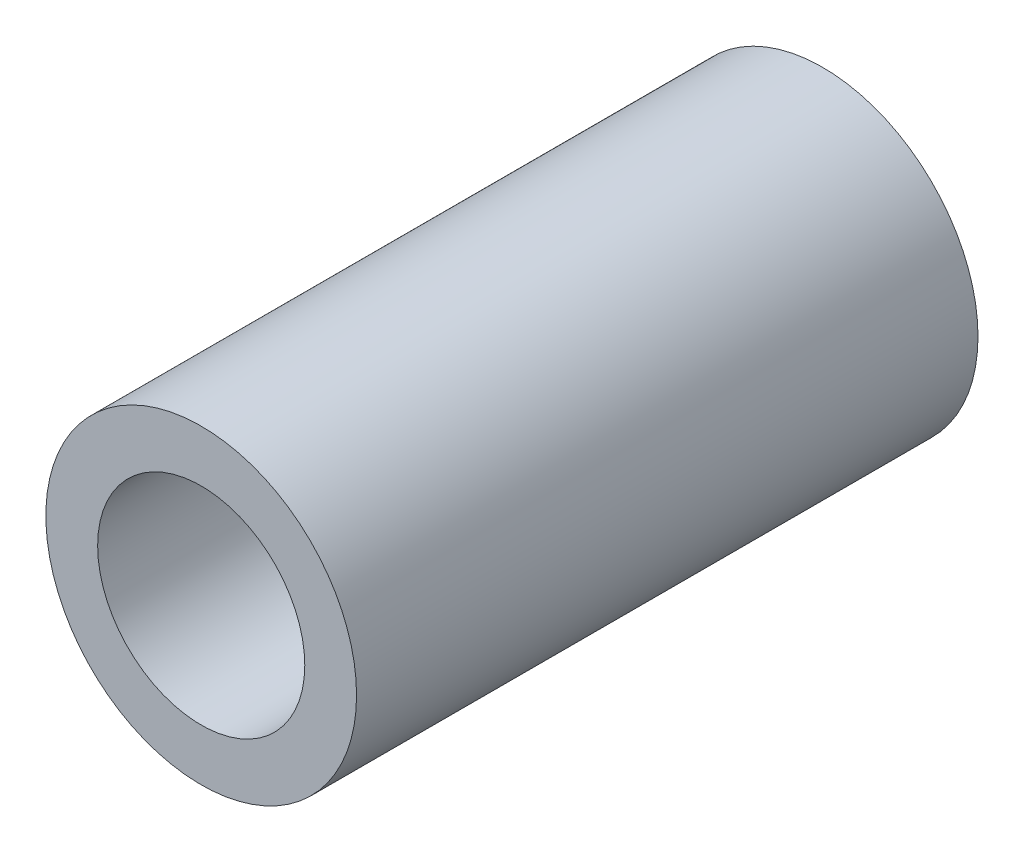
from build123d import *

# Parameters (mm, degrees)
SKETCH1_R           = 4.7625
SKETCH1_R_2         = 3.175
BOSS_EXTRUDE1_DEPTH = 19.05


with BuildPart() as part:
    # Sketch1 → Boss-Extrude1 (new body)
    with BuildSketch(Plane.XY):
        Circle(SKETCH1_R)
        Circle(SKETCH1_R_2, mode=Mode.SUBTRACT)
    extrude(amount=BOSS_EXTRUDE1_DEPTH)


solid = part.part
